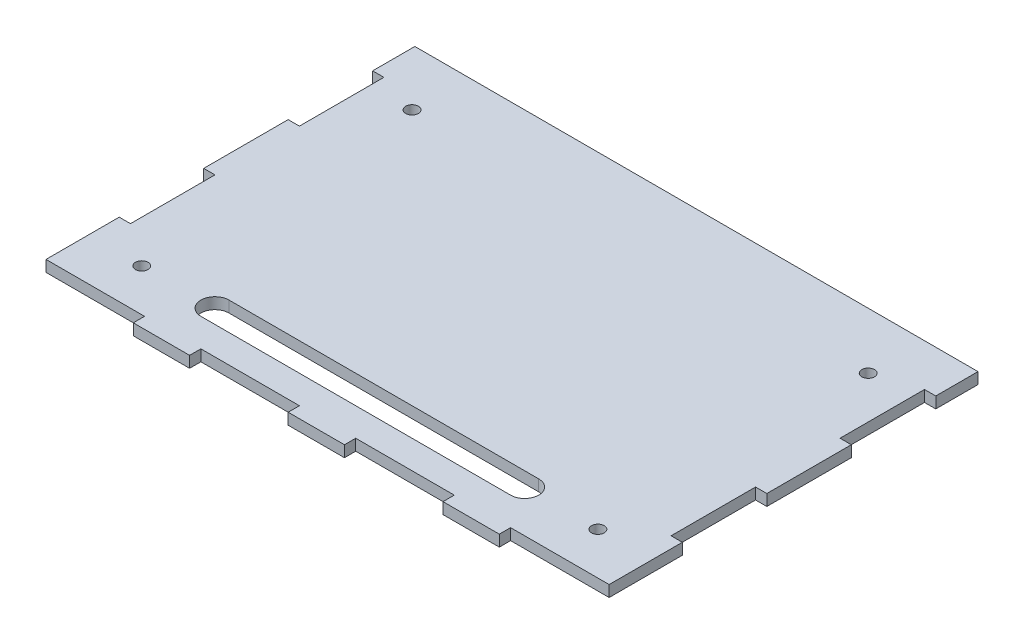
from build123d import *

# Parameters (mm, degrees)
ESBO_O1_W                               = 200
ESBO_O1_H                               = 150
RESSALTO_EXTRUS_O1_DEPTH                = 4
ESBO_O2_W                               = 35
ESBO_O2_H                               = 4
ESBO_O2_W_2                             = 4
ESBO_O2_H_2                             = 30
CORTE_EXTRUS_O1_DEPTH                   = 5
ESBO_O3_W                               = 200
ESBO_O3_H                               = 15
CORTE_EXTRUS_O2_DEPTH                   = 5
BROCA_DE_ROSQUEAR_PARA_TARRAXA_DE_M41_D = 4.5
ESBO_O5_R                               = 2.25
CORTE_EXTRUS_O3_DEPTH                   = 5


with BuildPart() as part:
    # Esboço1 → Ressalto-extrusão1 (new body)
    with BuildSketch(Plane(origin=(0, 0, 0), x_dir=(1, 0, 0), z_dir=(0, 1, 0))):
        Rectangle(ESBO_O1_W, ESBO_O1_H)
    extrude(amount=RESSALTO_EXTRUS_O1_DEPTH)

    # Esboço2 → Corte-extrusão1 (cut, through all)
    with BuildSketch(Plane(origin=(0, 4, 0), x_dir=(1, 0, 0), z_dir=(0, 1, 0))):
        with Locations((-27.5, -73)):
            Rectangle(ESBO_O2_W, ESBO_O2_H)
        with Locations((27.5, -73)):
            Rectangle(ESBO_O2_W, ESBO_O2_H)
        with Locations((82.5, -73)):
            Rectangle(ESBO_O2_W, ESBO_O2_H)
        with Locations((-82.5, -73)):
            Rectangle(ESBO_O2_W, ESBO_O2_H)
        with Locations((98, 30)):
            Rectangle(ESBO_O2_W_2, ESBO_O2_H_2)
        with Locations((98, -30)):
            Rectangle(ESBO_O2_W_2, ESBO_O2_H_2)
        with Locations((-98, 30)):
            Rectangle(ESBO_O2_W_2, ESBO_O2_H_2)
        with Locations((-98, -30)):
            Rectangle(ESBO_O2_W_2, ESBO_O2_H_2)
    extrude(amount=-CORTE_EXTRUS_O1_DEPTH, mode=Mode.SUBTRACT)

    # Esboço3 → Corte-extrusão2 (cut, through all)
    with BuildSketch(Plane(origin=(0, 4, 0), x_dir=(1, 0, 0), z_dir=(0, 1, 0))):
        with Locations((0, 67.5)):
            Rectangle(ESBO_O3_W, ESBO_O3_H)
    extrude(amount=-CORTE_EXTRUS_O2_DEPTH, mode=Mode.SUBTRACT)

    # Broca de rosquear para tarraxa de M41 (through all)
    with Locations(Plane(origin=(-81, 4, -40), x_dir=(0, 0, 1), z_dir=(0, 1, 0))):
        with Locations((0, 0), (96, 0), (96, 162), (0, 162)):
            Hole(BROCA_DE_ROSQUEAR_PARA_TARRAXA_DE_M41_D / 2)

    # Esboço5 → Corte-extrusão3 (cut, through all)
    with BuildSketch(Plane(origin=(0, 4, 0), x_dir=(1, 0, 0), z_dir=(0, 1, 0))):
        with Locations((-81, -56)):
            Circle(ESBO_O5_R)
        with BuildLine():
            Line((55, -61), (-55, -61))
            ThreePointArc((-55, -61), (-60, -56), (-55, -51))
            Line((-55, -51), (55, -51))
            ThreePointArc((55, -51), (60, -56), (55, -61))
        make_face()
    extrude(amount=-CORTE_EXTRUS_O3_DEPTH, mode=Mode.SUBTRACT)


solid = part.part
